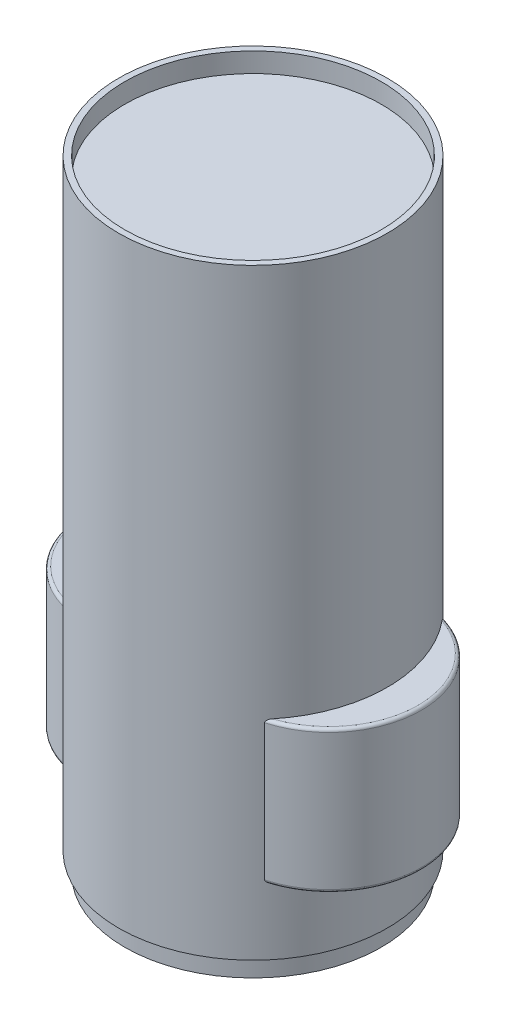
from build123d import *

# Parameters (mm, degrees)
EXTRUDE1_DEPTH = 47.07
EXTRUDE2_START = 100
EXTRUDE2_DEPTH = 100
FILLET1_R      = 1


with BuildPart() as part:
    # Sketch1 → Revolve1 (revolve)
    with BuildSketch(Plane(origin=(0, 0, 0), x_dir=(0, 0, -1), z_dir=(1, 0, 0))):
        Polygon((0, 0), (-42.5, 0), (-42.5, 6.5), (-44.5, 6.5), (-44.5, 205.8), (-42.5, 205.8), (-42.5, 199.3), (0, 199.3), align=None)
    revolve(axis=Axis((0, 199.3, 0), (0, -1, 0)))

    # Sketch2 → Extrude1 (add)
    with BuildSketch(Plane.XZ.offset(-28.5)):
        with BuildLine():
            ThreePointArc((0, -17.430935144), (55.75, 0), (0, 17.430935144))
            ThreePointArc((0, 17.430935144), (-55.75, 0), (0, -17.430935144))
        make_face()
    extrude(amount=-EXTRUDE1_DEPTH)

    # Sketch3 → Extrude2 (add)
    with BuildSketch(Plane(origin=(0, 75.57, 0), x_dir=(-1, 0, 0), z_dir=(0, 1, 0)).offset(EXTRUDE2_START)):
        with BuildLine():
            Line((48.03, 5), (48.03, -5))
            ThreePointArc((48.03, -5), (46.51379262, -6.562299411), (44.906801727, -5.093543292))
            ThreePointArc((44.906801727, -5.093543292), (44.566947891, -4.764619749), (44.209712274, -5.074577876))
            ThreePointArc((44.209712274, -5.074577876), (44.5, 0), (44.209712274, 5.074577876))
            ThreePointArc((44.209712274, 5.074577876), (44.566947891, 4.764619749), (44.906801727, 5.093543292))
            ThreePointArc((44.906801727, 5.093543292), (46.51379262, 6.562299411), (48.03, 5))
        make_face()
    extrude(amount=-EXTRUDE2_DEPTH)

    # Fillet1
    fillet1_edges = [part.edges().sort_by_distance(p)[0] for p in [
        (55.75, 28.5, 0),
        (55.75, 75.57, 0),
        (-55.75, 28.5, 0),
        (-55.75, 75.57, 0),
    ]]
    fillet(fillet1_edges, radius=FILLET1_R)


solid = part.part
